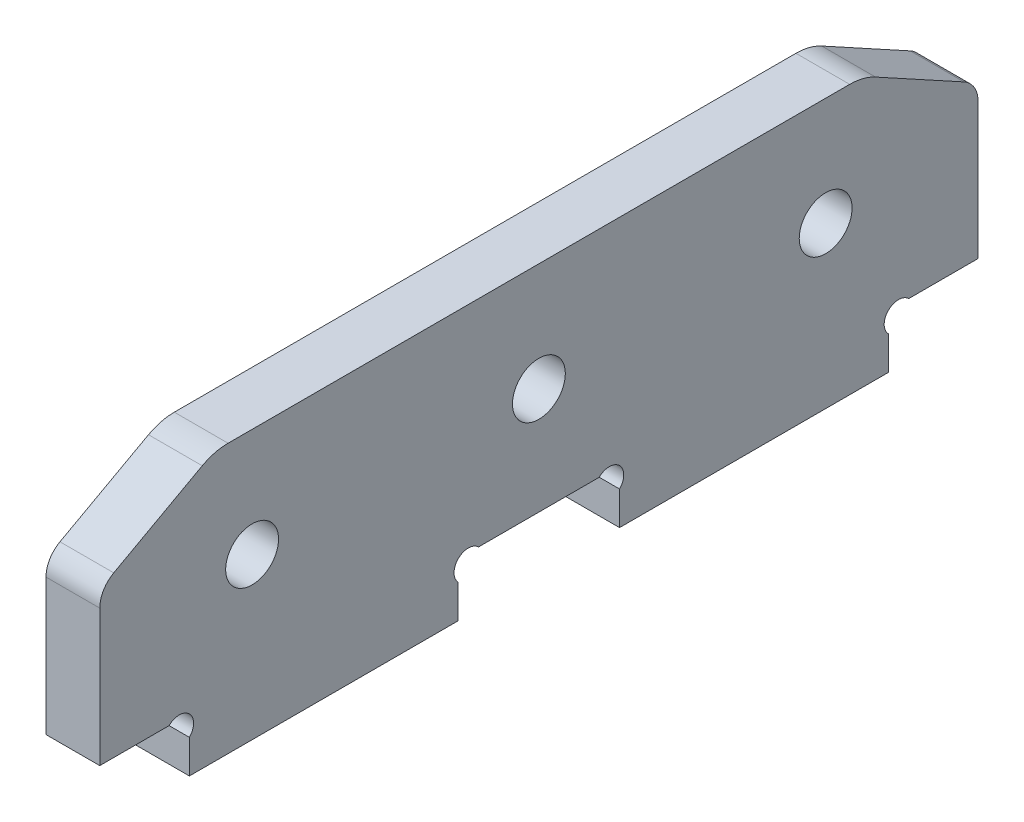
from build123d import *

# Parameters (mm, degrees)
ESQUISSE2_R      = 2.95
EXTRUSION1_DEPTH = 6


with BuildPart() as part:
    # Esquisse2 → Extrusion1 (new body)
    with BuildSketch(Plane(origin=(0, 0, 0), x_dir=(0, 0, -1), z_dir=(1, 0, 0))):
        with BuildLine():
            Line((1.559056131, 23.853768834), (11.436011282, 29.262577607))
            ThreePointArc((11.436011282, 29.262577607), (12.830529806, 29.812721636), (14.31789902, 30))
            Line((14.31789902, 30), (83.68210098, 30))
            ThreePointArc((83.68210098, 30), (85.169470194, 29.812721636), (86.563988718, 29.262577607))
            Line((86.563988718, 29.262577607), (96.440943869, 23.853768834))
            ThreePointArc((96.440943869, 23.853768834), (97.580971872, 22.751723045), (98, 21.22248003))
            Line((98, 21.22248003), (98, 6))
            Line((98, 6), (90.2627417, 6))
            ThreePointArc((90.2627417, 6), (88, 6), (88, 3.7372583))
            Line((88, 3.7372583), (88, 0))
            Line((88, 0), (58, 0))
            Line((58, 0), (58, 3.7372583))
            ThreePointArc((58, 3.7372583), (58, 6), (55.7372583, 6))
            Line((55.7372583, 6), (42.2627417, 6))
            ThreePointArc((42.2627417, 6), (40, 6), (40, 3.7372583))
            Line((40, 3.7372583), (40, 0))
            Line((40, 0), (10, 0))
            Line((10, 0), (10, 3.7372583))
            ThreePointArc((10, 3.7372583), (10, 6), (7.7372583, 6))
            Line((7.7372583, 6), (0, 6))
            Line((0, 6), (0, 21.22248003))
            ThreePointArc((0, 21.22248003), (0.419028128, 22.751723045), (1.559056131, 23.853768834))
        make_face()
        with Locations((17, 17.92)):
            Circle(ESQUISSE2_R, mode=Mode.SUBTRACT)
        with Locations(Location((81, 17.92, 0), (0, 0, 180))):  # turned: the seam where the file's is
            Circle(ESQUISSE2_R, mode=Mode.SUBTRACT)
        with Locations((49, 17.92)):
            Circle(ESQUISSE2_R, mode=Mode.SUBTRACT)
    extrude(amount=EXTRUSION1_DEPTH)


solid = part.part
